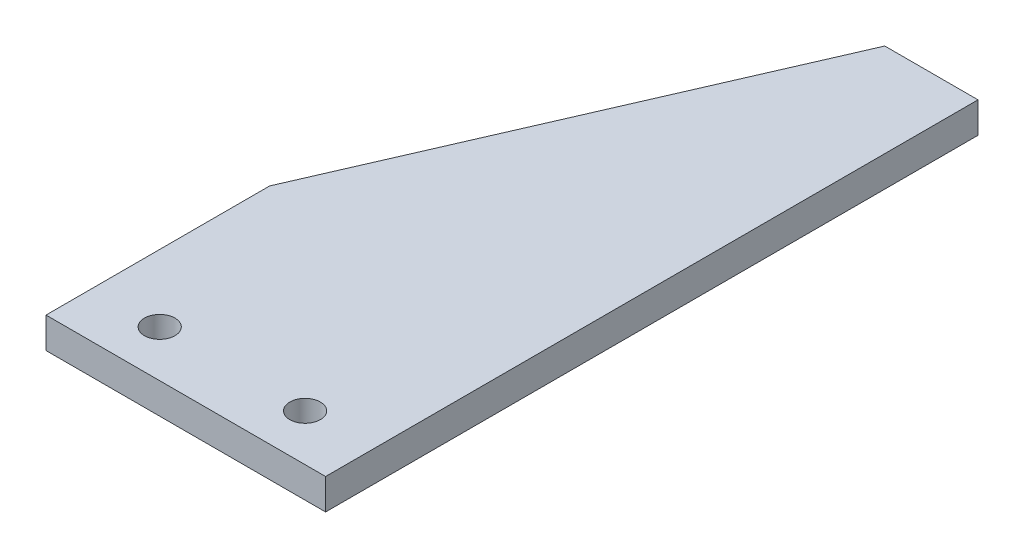
from build123d import *

# Parameters (mm, degrees)
SKETCH2_R           = 2.0828
BOSS_EXTRUDE1_DEPTH = 4.191


with BuildPart() as part:
    # Sketch2 → Boss-Extrude1 (new body)
    with BuildSketch(Plane(origin=(0, 0, 0), x_dir=(1, 0, 0), z_dir=(0, 1, 0))):
        Polygon((0, 0), (0, 30.48), (25.4, 88.9), (38.1, 88.9), (38.1, 0), align=None)
        with Locations((9.144, 6.35)):
            Circle(SKETCH2_R, mode=Mode.SUBTRACT)
        with Locations((28.956, 6.35)):
            Circle(SKETCH2_R, mode=Mode.SUBTRACT)
    extrude(amount=BOSS_EXTRUDE1_DEPTH)


solid = part.part
